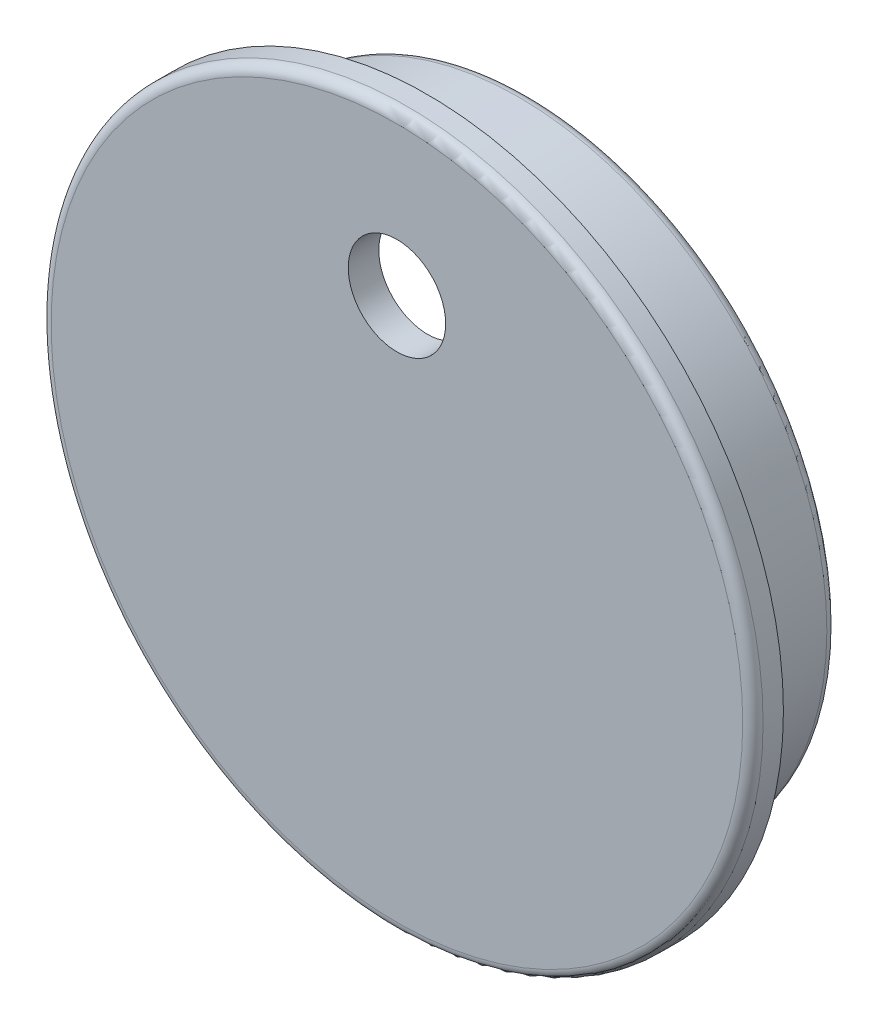
from build123d import *

# Parameters (mm, degrees)
SKETCH1_R           = 44.45
BOSS_EXTRUDE1_DEPTH = 3.81
SKETCH2_R           = 38.4429
SKETCH2_R_2         = 34.6329
BOSS_EXTRUDE2_DEPTH = 12.7
FILLET1_R           = 1.27
SKETCH4_R           = 6.0833
CUT_EXTRUDE1_DEPTH  = 17.51


with BuildPart() as part:
    # Sketch1 → Boss-Extrude1 (new body)
    with BuildSketch(Plane.XY):
        Circle(SKETCH1_R)
    extrude(amount=BOSS_EXTRUDE1_DEPTH)

    # Sketch2 → Boss-Extrude2 (add)
    with BuildSketch(Plane(origin=(0, 0, 0), x_dir=(-1, 0, 0), z_dir=(0, 0, -1))):
        Circle(SKETCH2_R)
        Circle(SKETCH2_R_2, mode=Mode.SUBTRACT)
    extrude(amount=BOSS_EXTRUDE2_DEPTH)

    # Fillet1
    fillet1_edges = [part.edges().sort_by_distance(p)[0] for p in [
        (-44.45, 0, 3.81),
        (38.4429, 0, -12.7),
        (34.6329, 0, 0),
        (34.6329, 0, -12.7),
    ]]
    fillet(fillet1_edges, radius=FILLET1_R)

    # Sketch4 → Cut-Extrude1 (cut, through all)
    with BuildSketch(Plane.XY.offset(3.81)):
        with Locations((0, 24.5999)):
            Circle(SKETCH4_R)
    extrude(amount=-CUT_EXTRUDE1_DEPTH, mode=Mode.SUBTRACT)


solid = part.part
